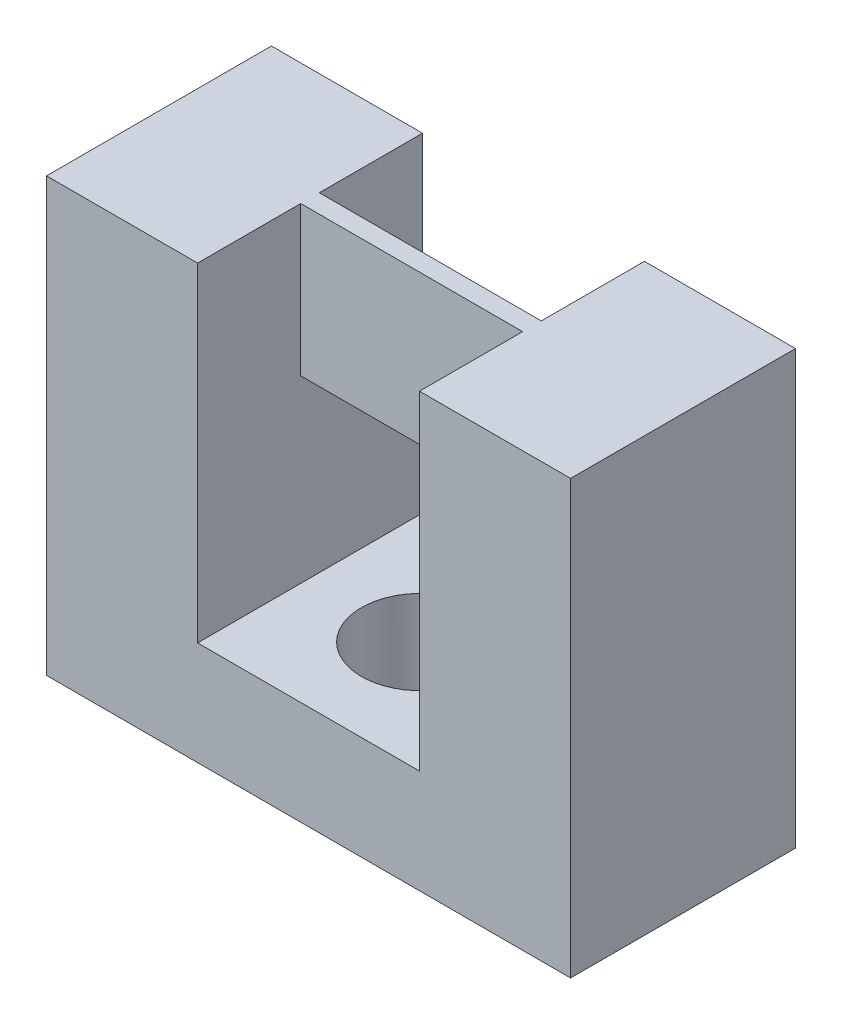
from build123d import *

# Parameters (mm, degrees)
SKETCH1_W                = 14.05
SKETCH1_H                = 11.6
BOSS_EXTRUDE1_DEPTH      = 6.03
SKETCH2_W                = 5.95
SKETCH2_H                = 8.82
CUT_EXTRUDE2_DEPTH       = 6.03
SKETCH3_W                = 0.5
SKETCH3_H                = 4
BOSS_EXTRUDE2_DEPTH      = 6.03
M3_CLEARANCE_HOLE1_D     = 3.2
M3_CLEARANCE_HOLE1_DEPTH = 2.78


with BuildPart() as part:
    # Sketch1 → Boss-Extrude1 (new body)
    with BuildSketch(Plane.XY):
        Rectangle(SKETCH1_W, SKETCH1_H)
    extrude(amount=BOSS_EXTRUDE1_DEPTH)

    # Sketch2 → Cut-Extrude2 (cut)
    with BuildSketch(Plane.XY.offset(6.03)):
        with Locations((0, 1.39)):
            Rectangle(SKETCH2_W, SKETCH2_H)
    extrude(amount=-CUT_EXTRUDE2_DEPTH, mode=Mode.SUBTRACT)

    # Sketch3 → Boss-Extrude2 (add)
    with BuildSketch(Plane(origin=(-2.975, 0, 0), x_dir=(0, 0, -1), z_dir=(1, 0, 0))):
        with Locations((-3.015, 3.8)):
            Rectangle(SKETCH3_W, SKETCH3_H)
    extrude(amount=BOSS_EXTRUDE2_DEPTH)

    # M3 Clearance Hole1
    with Locations(Plane(origin=(0, -5.8, 0), x_dir=(-1, 0, 0), z_dir=(0, -1, 0))):
        with Locations((0, -3.015)):
            Hole(M3_CLEARANCE_HOLE1_D / 2, depth=M3_CLEARANCE_HOLE1_DEPTH)


solid = part.part
